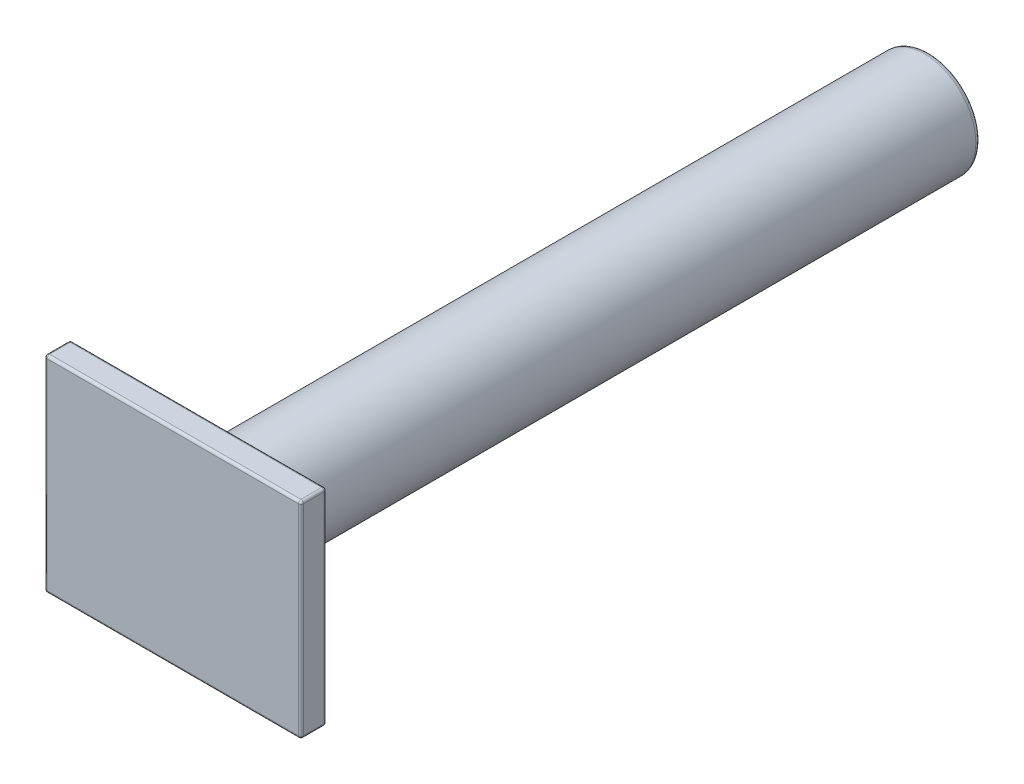
from build123d import *

# Parameters (mm, degrees)
SKETCH1_R           = 20
BOSS_EXTRUDE1_DEPTH = 284
SKETCH2_W           = 99.610894942
SKETCH2_H           = 80
BOSS_EXTRUDE2_DEPTH = 10
FILLET1_R           = 2
FILLET2_R           = 1


with BuildPart() as part:
    # Sketch1 → Boss-Extrude1 (new body)
    with BuildSketch(Plane.XY):
        Circle(SKETCH1_R)
    extrude(amount=BOSS_EXTRUDE1_DEPTH)

    # Sketch2 → Boss-Extrude2 (add)
    with BuildSketch(Plane.XY.offset(284)):
        Rectangle(SKETCH2_W, SKETCH2_H)
    extrude(amount=BOSS_EXTRUDE2_DEPTH)

    # Fillet1
    fillet1_edges = [part.edges().sort_by_distance(p)[0] for p in [
        (-20, 0, 0),
    ]]
    fillet(fillet1_edges, radius=FILLET1_R)

    # Fillet2
    fillet2_edges = [part.edges().sort_by_distance(p)[0] for p in [
        (49.805447471, 0, 284),
        (49.805447471, -40, 289),
        (0, 40, 284),
        (49.805447471, 40, 289),
        (-49.805447471, 0, 284),
        (-49.805447471, 40, 289),
        (0, -40, 284),
        (-49.805447471, -40, 289),
        (49.805447471, 0, 294),
        (0, 40, 294),
        (-49.805447471, 0, 294),
        (0, -40, 294),
    ]]
    fillet(fillet2_edges, radius=FILLET2_R)


solid = part.part
